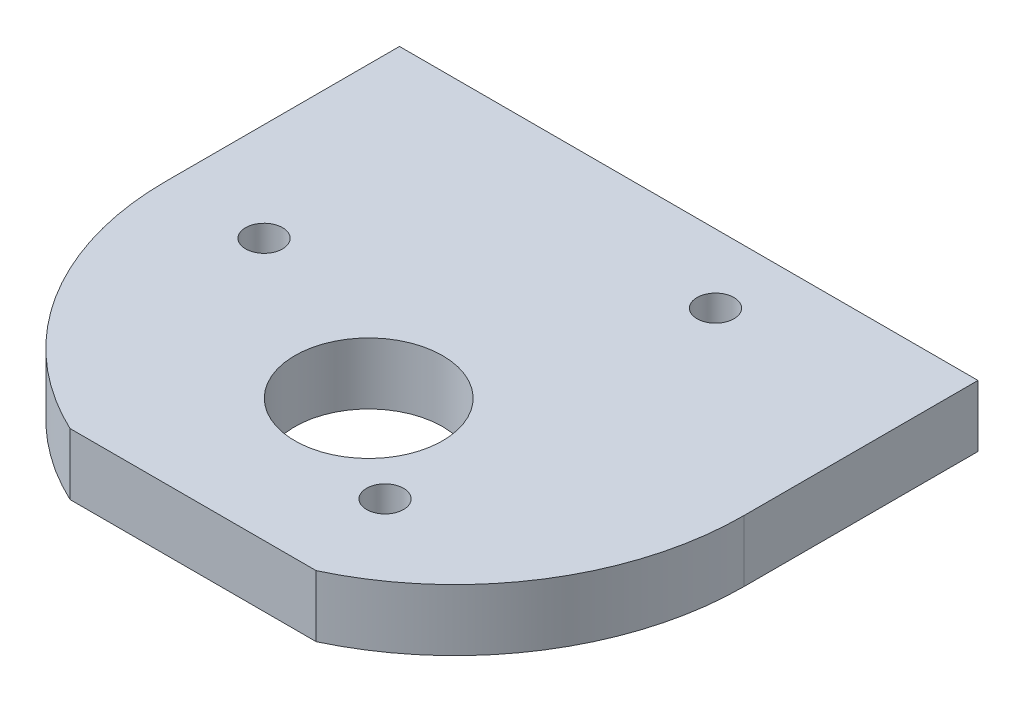
from build123d import *

# Parameters (mm, degrees)
SKETCH_1_W          = 47
SKETCH_1_H          = 5
EXTRUDE_1_DEPTH     = 19
SKETCH_2_R          = 23.5
EXTRUDE_2_DEPTH     = 5
SKETCH_3_R          = 6
SKETCH_3_R_2        = 1.5
CUT_EXTRUDE_1_DEPTH = 5
M2_5X0_45_1_D       = 2.05
M2_5X0_45_1_DEPTH   = 7.25
M2_5X0_45_1_TIP     = 0.615882135
CUT_EXTRUDE_2_DEPTH = 5
CUT_EXTRUDE_3_DEPTH = 5


with BuildPart() as part:
    # ｽｹｯﾁ1 → ﾎﾞｽ - 押し出し1 (new body)
    with BuildSketch(Plane.XY):
        Rectangle(SKETCH_1_W, SKETCH_1_H)
    extrude(amount=EXTRUDE_1_DEPTH)

    # ｽｹｯﾁ2 → ﾎﾞｽ - 押し出し2 (add)
    with BuildSketch(Plane.XZ.offset(2.5)):
        with Locations((0, 19)):
            Circle(SKETCH_2_R)
    extrude(amount=-EXTRUDE_2_DEPTH)

    # ｽｹｯﾁ3 → ｶｯﾄ - 押し出し1 (cut)
    with BuildSketch(Plane.XZ.offset(2.5)):
        with Locations(Location((0, 26, 0), (0, 0, 270))):  # turned: the seam where the file's is
            Circle(SKETCH_3_R)
        with Locations(Location((-15.5, 19, 0), (0, 0, 270))):  # turned: the seam where the file's is
            Circle(SKETCH_3_R_2)
        with Locations(Location((7.75, 5.576606241, 0), (0, 0, 270))):  # turned: the seam where the file's is
            Circle(SKETCH_3_R_2)
        with Locations(Location((7.75, 32.423393759, 0), (0, 0, 270))):  # turned: the seam where the file's is
            Circle(SKETCH_3_R_2)
    extrude(amount=-CUT_EXTRUDE_1_DEPTH, mode=Mode.SUBTRACT)

    # M2.5x0.45 ねじ穴1
    with Locations(Plane(origin=(0, 0, 0), x_dir=(-1, 0, 0), z_dir=(0, 0, -1))):
        with Locations((18, 0), (-18, 0)):
            Hole(M2_5X0_45_1_D / 2, depth=M2_5X0_45_1_DEPTH)
            with Locations((0, 0, -(M2_5X0_45_1_DEPTH + M2_5X0_45_1_TIP / 2))):  # 118° drill point
                Cone(0, M2_5X0_45_1_D / 2, M2_5X0_45_1_TIP, mode=Mode.SUBTRACT)

    # ｽｹｯﾁ8 → ｶｯﾄ - 押し出し2 (cut)
    with BuildSketch(Plane(origin=(0, 2.5, 0), x_dir=(1, 0, 0), z_dir=(0, 1, 0))):
        with BuildLine():
            Line((-13.829316686, 0), (13.829316686, 0))
            ThreePointArc((13.829316686, 0), (0, 4.5), (-13.829316686, 0))
        make_face()
    extrude(amount=-CUT_EXTRUDE_2_DEPTH, mode=Mode.SUBTRACT)

    # ｽｹｯﾁ9 → ｶｯﾄ - 押し出し3 (cut)
    with BuildSketch(Plane(origin=(0, 2.5, 0), x_dir=(1, 0, 0), z_dir=(0, 1, 0))):
        with BuildLine():
            Line((-10, -40.266170318), (10, -40.266170318))
            ThreePointArc((10, -40.266170318), (0, -42.5), (-10, -40.266170318))
        make_face()
    extrude(amount=-CUT_EXTRUDE_3_DEPTH, mode=Mode.SUBTRACT)


solid = part.part
